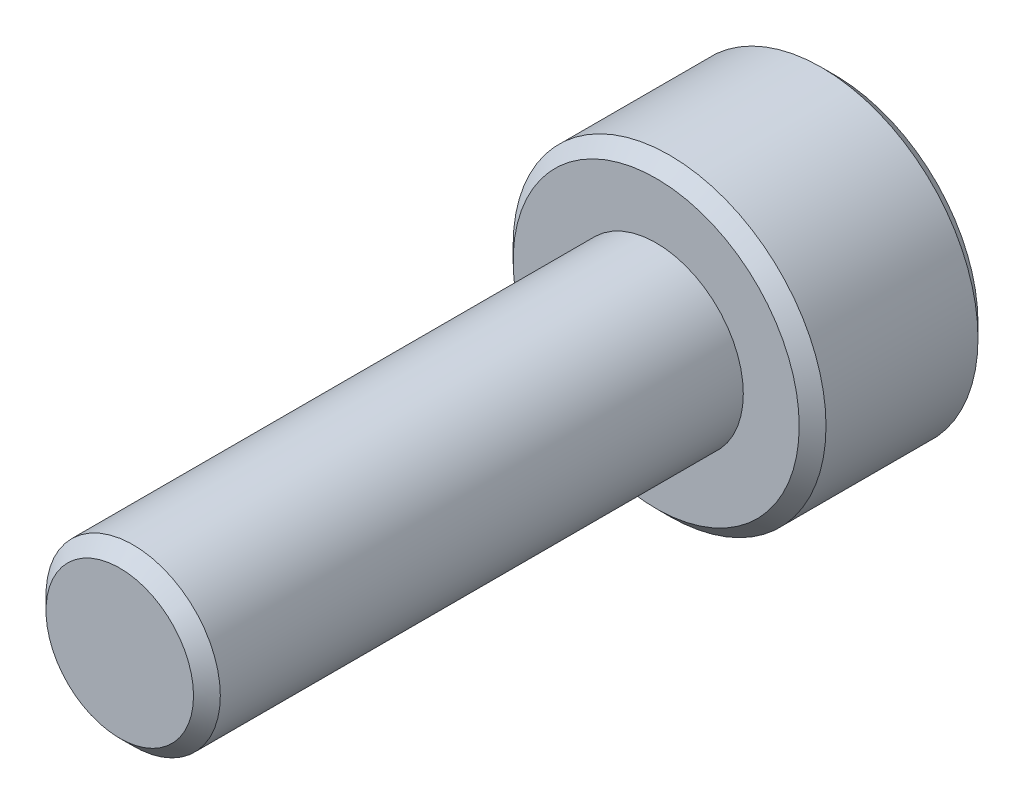
from build123d import *

# Parameters (mm, degrees)
SKIZZE1_R                       = 3.5
AUFSATZ_LINEAR_AUSTRAGEN1_DEPTH = 4
SKIZZE2_R                       = 1.95
AUFSATZ_LINEAR_AUSTRAGEN2_DEPTH = 12
FASE1_SIZE                      = 0.3
SCHNITT_LINEAR_AUSTRAGEN1_DEPTH = 2.5


with BuildPart() as part:
    # Skizze1 → Aufsatz-Linear austragen1 (new body)
    with BuildSketch(Plane.XY):
        Circle(SKIZZE1_R)
    extrude(amount=AUFSATZ_LINEAR_AUSTRAGEN1_DEPTH)

    # Skizze2 → Aufsatz-Linear austragen2 (add)
    with BuildSketch(Plane.XY.offset(4)):
        Circle(SKIZZE2_R)
    extrude(amount=AUFSATZ_LINEAR_AUSTRAGEN2_DEPTH)

    # Fase1
    fase1_edges = [part.edges().sort_by_distance(p)[0] for p in [
        (-3.5, 0, 0),
        (-3.5, 0, 4),
        (-1.95, 0, 16),
    ]]
    chamfer(fase1_edges, length=FASE1_SIZE)

    # Skizze3 → Schnitt-Linear austragen1 (cut)
    with BuildSketch(Plane(origin=(0, 0, 0), x_dir=(-1, 0, 0), z_dir=(0, 0, -1))):
        Polygon((1.5, 0.866025404), (0, 1.732050808), (-1.5, 0.866025404), (-1.5, -0.866025404), (0, -1.732050808), (1.5, -0.866025404), align=None)
    extrude(amount=-SCHNITT_LINEAR_AUSTRAGEN1_DEPTH, mode=Mode.SUBTRACT)


solid = part.part
